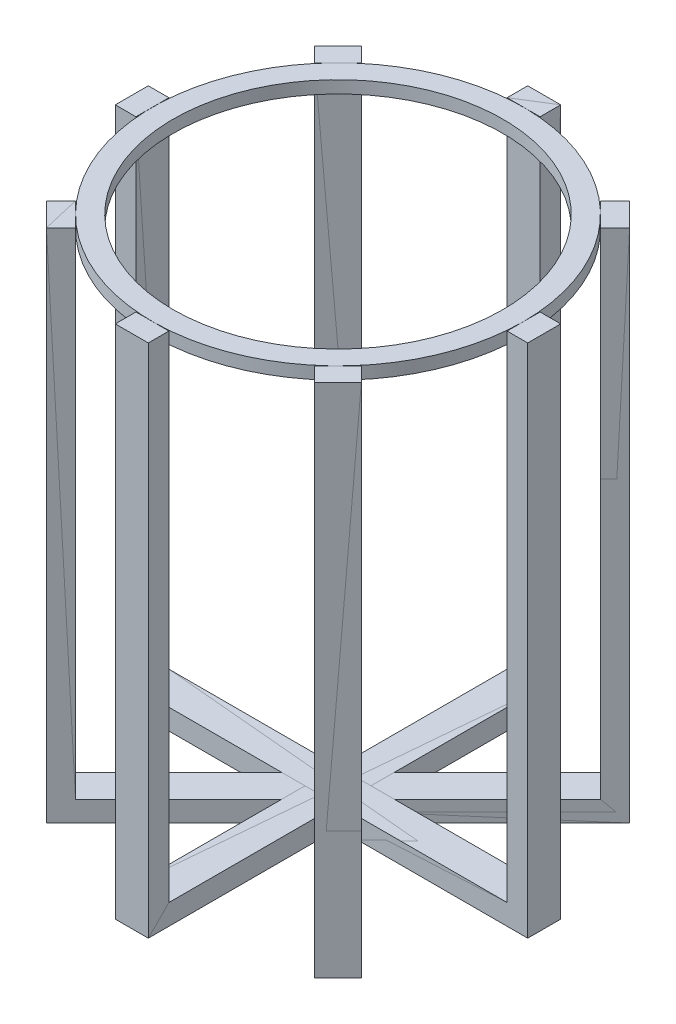
from build123d import *

# Parameters (mm, degrees)
SKETCH1_R           = 45
SKETCH1_R_2         = 40
EXTRUDE_THIN1_DEPTH = 3
EXTRUDE_THIN2_DEPTH = 4
CIRPATTERN4_COUNT   = 8


with BuildPart() as part:
    # Sketch1 → Extrude-Thin1 (new body)
    with BuildSketch(Plane(origin=(0, 0, 0), x_dir=(1, 0, 0), z_dir=(0, 1, 0))):
        Circle(SKETCH1_R)
        Circle(SKETCH1_R_2, mode=Mode.SUBTRACT)
    extrude(amount=EXTRUDE_THIN1_DEPTH)


with BuildPart() as body_2:
    # Sketch2 → Extrude-Thin2 (new body, symmetric)
    with BuildSketch(Plane.XY):
        Polygon((45, 3), (45, -117), (-45, -117), (-45, 3), (-50, 3), (-50, -122), (50, -122), (50, 3), align=None)
    extrude(amount=EXTRUDE_THIN2_DEPTH, both=True)


with BuildPart() as cirpattern4_1:
    # CirPattern4: pattern copy
    add(body_2.part.rotate(Axis((0, 0, 0), (0, 1, 0)), 1 * 360 / CIRPATTERN4_COUNT))


with BuildPart() as cirpattern4_2:
    # CirPattern4: pattern copy
    add(body_2.part.rotate(Axis((0, 0, 0), (0, 1, 0)), 2 * 360 / CIRPATTERN4_COUNT))


with BuildPart() as cirpattern4_3:
    # CirPattern4: pattern copy
    add(body_2.part.rotate(Axis((0, 0, 0), (0, 1, 0)), 3 * 360 / CIRPATTERN4_COUNT))


with BuildPart() as cirpattern4_4:
    # CirPattern4: pattern copy
    add(body_2.part.rotate(Axis((0, 0, 0), (0, 1, 0)), 4 * 360 / CIRPATTERN4_COUNT))


with BuildPart() as cirpattern4_5:
    # CirPattern4: pattern copy
    add(body_2.part.rotate(Axis((0, 0, 0), (0, 1, 0)), 5 * 360 / CIRPATTERN4_COUNT))


with BuildPart() as cirpattern4_6:
    # CirPattern4: pattern copy
    add(body_2.part.rotate(Axis((0, 0, 0), (0, 1, 0)), 6 * 360 / CIRPATTERN4_COUNT))


with BuildPart() as cirpattern4_7:
    # CirPattern4: pattern copy
    add(body_2.part.rotate(Axis((0, 0, 0), (0, 1, 0)), 7 * 360 / CIRPATTERN4_COUNT))


solid = Compound([part.part, body_2.part, cirpattern4_1.part, cirpattern4_2.part, cirpattern4_3.part, cirpattern4_4.part, cirpattern4_5.part, cirpattern4_6.part, cirpattern4_7.part])
